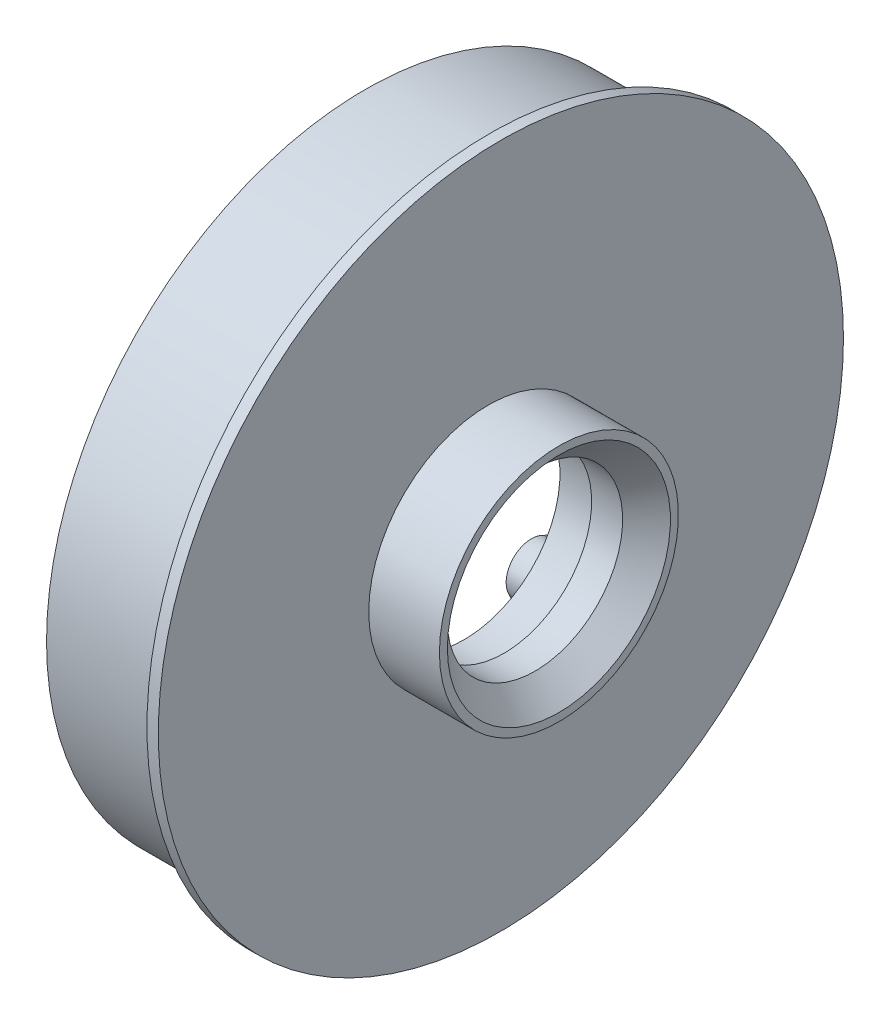
from build123d import *

# Parameters (mm, degrees)
BOSS_EXTRUDE1_START = 4.0094
SKETCH6_R           = 43.000000106
BOSS_EXTRUDE1_DEPTH = 17.0304
CUT_EXTRUDE1_START  = 4.0094
SKETCH7_R           = 43.000000106
SKETCH7_R_2         = 40.00000001
CUT_EXTRUDE1_DEPTH  = 15.60215


with BuildPart() as part:
    # Sketch5 → Revolve1 (revolve)
    with BuildSketch(Plane.XY):
        Polygon((23.019799782, 10.999999971), (23.019799782, 12.000000003), (18.039799836, 12.000000003), (18.039799836, 31.75), (18.039799836, 35.875000005), (21.039799932, 35.875000005), (21.039799932, 14.999999972), (22.939799942, 14.999999972), (29.909799972, 14.999999972), (29.909799972, 13.99999994), (26.909800003, 10.999999971), align=None)
    revolve(axis=Axis((0, 0, 0), (1, 0, 0)))

    # Sketch6 → Boss-Extrude1 (add)
    with BuildSketch(Plane(origin=(0, 0, 0), x_dir=(0, 0, -1), z_dir=(1, 0, 0)).offset(BOSS_EXTRUDE1_START)):
        with Locations((1.5875, 0)):
            Circle(SKETCH6_R)
        with BuildLine():
            ThreePointArc((-23.952340618, 19.653227004), (-27.928292299, 18.661088308), (-27.323378098, 14.608112886))
            ThreePointArc((-27.323378098, 14.608112886), (-26.399857642, 10.93517908), (-29.65004162, 8.991050256))
            ThreePointArc((-29.65004162, 8.991050256), (-32.943666958, 6.552902785), (-30.833792563, 3.039932389))
            ThreePointArc((-30.833792563, 3.039932389), (-28.575, 0), (-30.833792563, -3.039932389))
            ThreePointArc((-30.833792563, -3.039932389), (-32.943666958, -6.552902785), (-29.65004162, -8.991050256))
            ThreePointArc((-29.65004162, -8.991050256), (-26.399857642, -10.93517908), (-27.323378098, -14.608112886))
            ThreePointArc((-27.323378098, -14.608112886), (-27.928292299, -18.661088308), (-23.952340618, -19.653227004))
            ThreePointArc((-23.952340618, -19.653227004), (-20.205576272, -20.205576272), (-19.653227004, -23.952340618))
            ThreePointArc((-19.653227004, -23.952340618), (-18.661088308, -27.928292299), (-14.608112886, -27.323378098))
            ThreePointArc((-14.608112886, -27.323378098), (-10.93517908, -26.399857642), (-8.991050256, -29.65004162))
            ThreePointArc((-8.991050256, -29.65004162), (-6.552902785, -32.943666958), (-3.039932389, -30.833792563))
            ThreePointArc((-3.039932389, -30.833792563), (0, -28.575), (3.039932389, -30.833792563))
            ThreePointArc((3.039932389, -30.833792563), (6.552902785, -32.943666958), (8.991050256, -29.65004162))
            ThreePointArc((8.991050256, -29.65004162), (10.93517908, -26.399857642), (14.608112886, -27.323378098))
            ThreePointArc((14.608112886, -27.323378098), (18.661088308, -27.928292299), (19.653227004, -23.952340618))
            ThreePointArc((19.653227004, -23.952340618), (20.205576272, -20.205576272), (23.952340618, -19.653227004))
            ThreePointArc((23.952340618, -19.653227004), (27.928292299, -18.661088308), (27.323378098, -14.608112886))
            ThreePointArc((27.323378098, -14.608112886), (26.399857642, -10.93517908), (29.65004162, -8.991050256))
            ThreePointArc((29.65004162, -8.991050256), (32.943666958, -6.552902785), (30.833792563, -3.039932389))
            ThreePointArc((30.833792563, -3.039932389), (28.575, 0), (30.833792563, 3.039932389))
            ThreePointArc((30.833792563, 3.039932389), (32.943666958, 6.552902785), (29.65004162, 8.991050256))
            ThreePointArc((29.65004162, 8.991050256), (26.399857642, 10.93517908), (27.323378098, 14.608112886))
            ThreePointArc((27.323378098, 14.608112886), (27.928292299, 18.661088308), (23.952340618, 19.653227004))
            ThreePointArc((23.952340618, 19.653227004), (20.205576272, 20.205576272), (19.653227004, 23.952340618))
            ThreePointArc((19.653227004, 23.952340618), (18.661088308, 27.928292299), (14.608112886, 27.323378098))
            ThreePointArc((14.608112886, 27.323378098), (10.93517908, 26.399857642), (8.991050256, 29.65004162))
            ThreePointArc((8.991050256, 29.65004162), (6.552902785, 32.943666958), (3.039932389, 30.833792563))
            ThreePointArc((3.039932389, 30.833792563), (0, 28.575), (-3.039932389, 30.833792563))
            ThreePointArc((-3.039932389, 30.833792563), (-6.552902785, 32.943666958), (-8.991050256, 29.65004162))
            ThreePointArc((-8.991050256, 29.65004162), (-10.93517908, 26.399857642), (-14.608112886, 27.323378098))
            ThreePointArc((-14.608112886, 27.323378098), (-18.661088308, 27.928292299), (-19.653227004, 23.952340618))
            ThreePointArc((-19.653227004, 23.952340618), (-20.205576272, 20.205576272), (-23.952340618, 19.653227004))
        make_face(mode=Mode.SUBTRACT)
    extrude(amount=BOSS_EXTRUDE1_DEPTH)

    # Sketch7 → Cut-Extrude1 (cut)
    with BuildSketch(Plane(origin=(0, 0, 0), x_dir=(0, 0, -1), z_dir=(1, 0, 0)).offset(CUT_EXTRUDE1_START)):
        with Locations((1.5875, 0)):
            Circle(SKETCH7_R)
        with Locations((1.5875, 0)):
            Circle(SKETCH7_R_2, mode=Mode.SUBTRACT)
    extrude(amount=CUT_EXTRUDE1_DEPTH, mode=Mode.SUBTRACT)


solid = part.part
